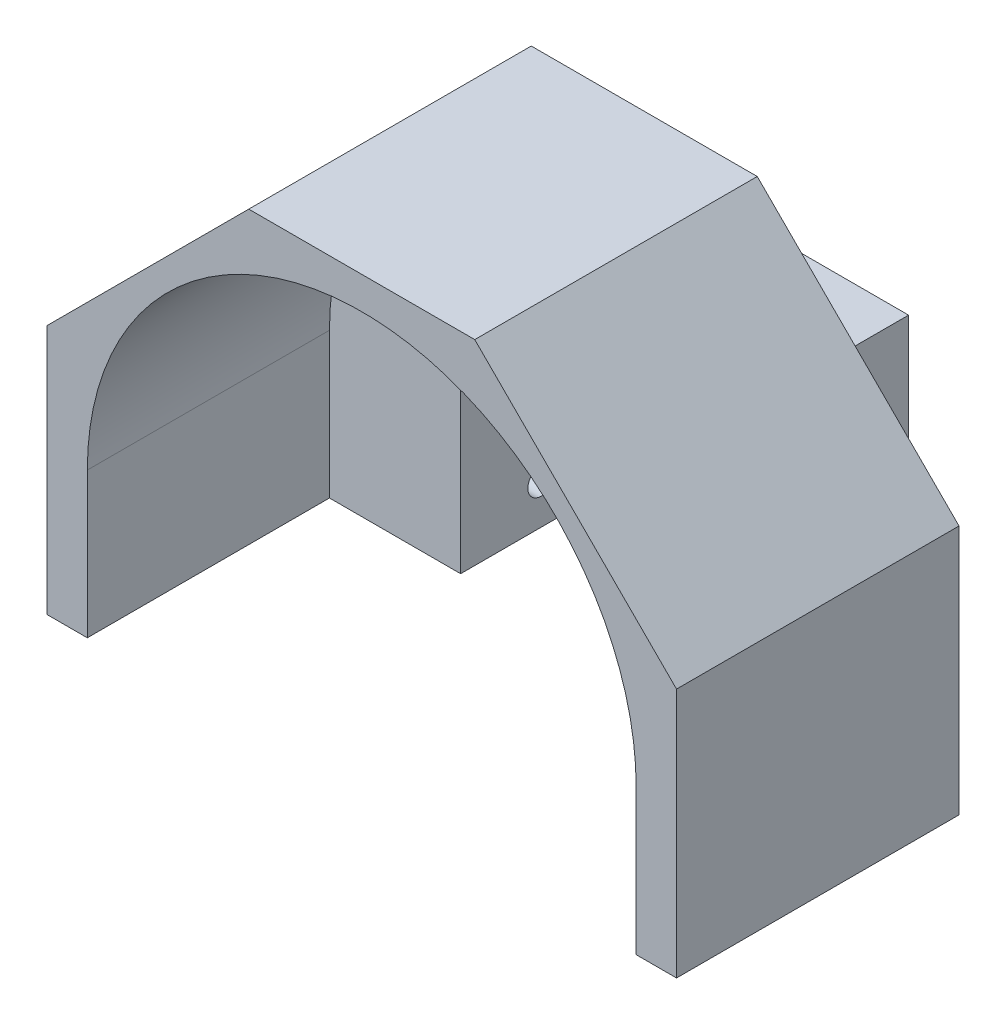
from build123d import *

# Parameters (mm, degrees)
ESQUISSE3_W              = 78
ESQUISSE3_H              = 56
BOSS_EXTRU_2_DEPTH       = 45
ESQUISSE4_R              = 34
ENL_V_MAT_EXTRU_1_DEPTH  = 30
ESQUISSE5_W              = 35.5
ESQUISSE5_H              = 35.5
ENL_V_MAT_EXTRU_2_DEPTH  = 15
ENL_V_MAT_EXTRU_5_DEPTH  = 10
ESQUISSE12_W             = 68
ESQUISSE12_H             = 18
ENL_V_MAT_EXTRU_6_DEPTH  = 30
ESQUISSE13_R             = 1.671466639
ENL_V_MAT_EXTRU_7_DEPTH  = 62.75
ESQUISSE15_R             = 1.5
ENL_V_MAT_EXTRU_8_DEPTH  = 62.75
ESQUISSE16_W             = 8
ESQUISSE16_H             = 8
ENL_V_MAT_EXTRU_9_DEPTH  = 4
ESQUISSE17_R             = 1.5
ENL_V_MAT_EXTRU_10_DEPTH = 41.5
ESQUISSE18_R             = 1.5
ENL_V_MAT_EXTRU_11_DEPTH = 41.5
ESQUISSE19_W             = 8
ESQUISSE19_H             = 8
ENL_V_MAT_EXTRU_12_DEPTH = 4
ENL_V_MAT_EXTRU_13_DEPTH = 46


with BuildPart() as part:
    # Esquisse3 → Boss.-Extru.2 (new body)
    with BuildSketch(Plane.XY):
        Rectangle(ESQUISSE3_W, ESQUISSE3_H)
    extrude(amount=BOSS_EXTRU_2_DEPTH)

    # Esquisse4 → Enlèv. mat.-Extru.1 (cut)
    with BuildSketch(Plane.XY.offset(45)):
        with Locations((0, -10)):
            Circle(ESQUISSE4_R)
    extrude(amount=-ENL_V_MAT_EXTRU_1_DEPTH, mode=Mode.SUBTRACT)

    # Esquisse5 → Enlèv. mat.-Extru.2 (cut)
    with BuildSketch(Plane(origin=(0, 0, 0), x_dir=(-1, 0, 0), z_dir=(0, 0, -1))):
        with Locations((0, -10.25)):
            Rectangle(ESQUISSE5_W, ESQUISSE5_H)
    extrude(amount=-ENL_V_MAT_EXTRU_2_DEPTH, mode=Mode.SUBTRACT)

    # Esquisse8 → Enlèv. mat.-Extru.5 (cut)
    with BuildSketch(Plane(origin=(0, 0, 0), x_dir=(-1, 0, 0), z_dir=(0, 0, -1))):
        Polygon((-22.75, -28), (-22.75, 12.5), (22.75, 12.5), (22.75, -28), (39, -28), (39, 28), (-39, 28), (-39, -28), align=None)
    extrude(amount=-ENL_V_MAT_EXTRU_5_DEPTH, mode=Mode.SUBTRACT)

    # Esquisse12 → Enlèv. mat.-Extru.6 (cut)
    with BuildSketch(Plane.XY.offset(45)):
        with Locations((0, -19)):
            Rectangle(ESQUISSE12_W, ESQUISSE12_H)
    extrude(amount=-ENL_V_MAT_EXTRU_6_DEPTH, mode=Mode.SUBTRACT)

    # Esquisse13 → Enlèv. mat.-Extru.7 (cut, through all)
    with BuildSketch(Plane.ZY.offset(22.75)):
        with Locations((5, -23)):
            Circle(ESQUISSE13_R)
    extrude(amount=-ENL_V_MAT_EXTRU_7_DEPTH, mode=Mode.SUBTRACT)

    # Esquisse15 → Enlèv. mat.-Extru.8 (cut, through all)
    with BuildSketch(Plane.ZY.offset(22.75)):
        with Locations((5, 2.5)):
            Circle(ESQUISSE15_R)
    extrude(amount=-ENL_V_MAT_EXTRU_8_DEPTH, mode=Mode.SUBTRACT)

    # Esquisse16 → Enlèv. mat.-Extru.9 (cut)
    with BuildSketch(Plane.XY.offset(15)):
        with Locations((-17.75, 7.5)):
            Rectangle(ESQUISSE16_W, ESQUISSE16_H)
    extrude(amount=-ENL_V_MAT_EXTRU_9_DEPTH, mode=Mode.SUBTRACT)

    # Esquisse17 → Enlèv. mat.-Extru.10 (cut, through all)
    with BuildSketch(Plane(origin=(0, 12.5, 0), x_dir=(1, 0, 0), z_dir=(0, 1, 0))):
        with Locations((-12.75, -5)):
            Circle(ESQUISSE17_R)
    extrude(amount=-ENL_V_MAT_EXTRU_10_DEPTH, mode=Mode.SUBTRACT)

    # Esquisse18 → Enlèv. mat.-Extru.11 (cut, through all)
    with BuildSketch(Plane(origin=(0, 12.5, 0), x_dir=(1, 0, 0), z_dir=(0, 1, 0))):
        with Locations((12.75, -5)):
            Circle(ESQUISSE18_R)
    extrude(amount=-ENL_V_MAT_EXTRU_11_DEPTH, mode=Mode.SUBTRACT)

    # Esquisse19 → Enlèv. mat.-Extru.12 (cut)
    with BuildSketch(Plane.XY.offset(15)):
        with Locations((17.75, 7.5)):
            Rectangle(ESQUISSE19_W, ESQUISSE19_H)
    extrude(amount=-ENL_V_MAT_EXTRU_12_DEPTH, mode=Mode.SUBTRACT)

    # Esquisse20 → Enlèv. mat.-Extru.13 (cut, through all)
    with BuildSketch(Plane.XY.offset(45)):
        Polygon((-39, 3), (-39, 28), (-14, 28), align=None)
    enl_v_mat_extru_13 = extrude(amount=-ENL_V_MAT_EXTRU_13_DEPTH, mode=Mode.SUBTRACT)

    # Symétrie1: Enlèv. mat.-Extru.13 across plane
    add(enl_v_mat_extru_13.mirror(Plane(origin=(0, 0, 0), x_dir=(0, 0, 1), z_dir=(1, 0, 0))), mode=Mode.SUBTRACT)


solid = part.part
